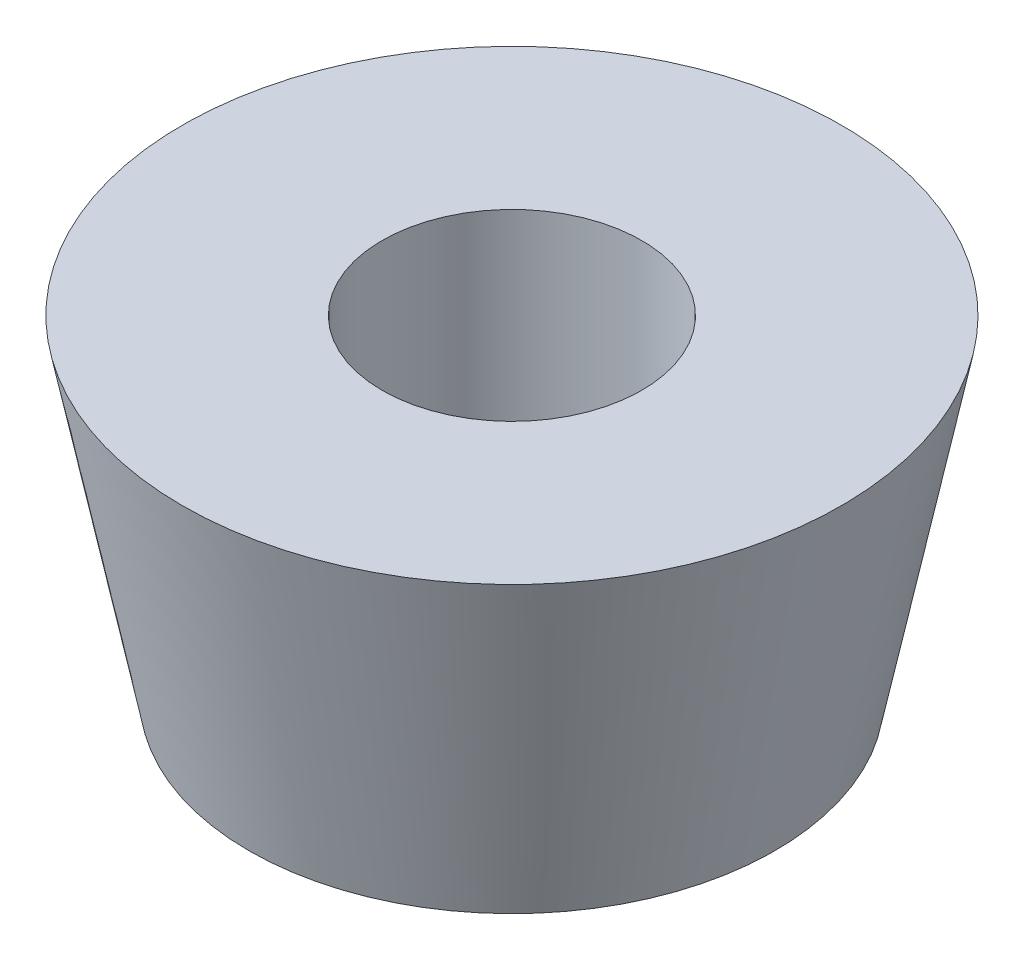
from build123d import *


with BuildPart() as part:
    # Sketch1 → Revolve1 (revolve)
    with BuildSketch(Plane.XY):
        Polygon((1.95, 0), (1.95, -4.988791046), (3.95, -4.988791046), (4.95, 0), align=None)
    revolve(axis=Axis((0, 0, 0), (0, -1, 0)))


solid = part.part
